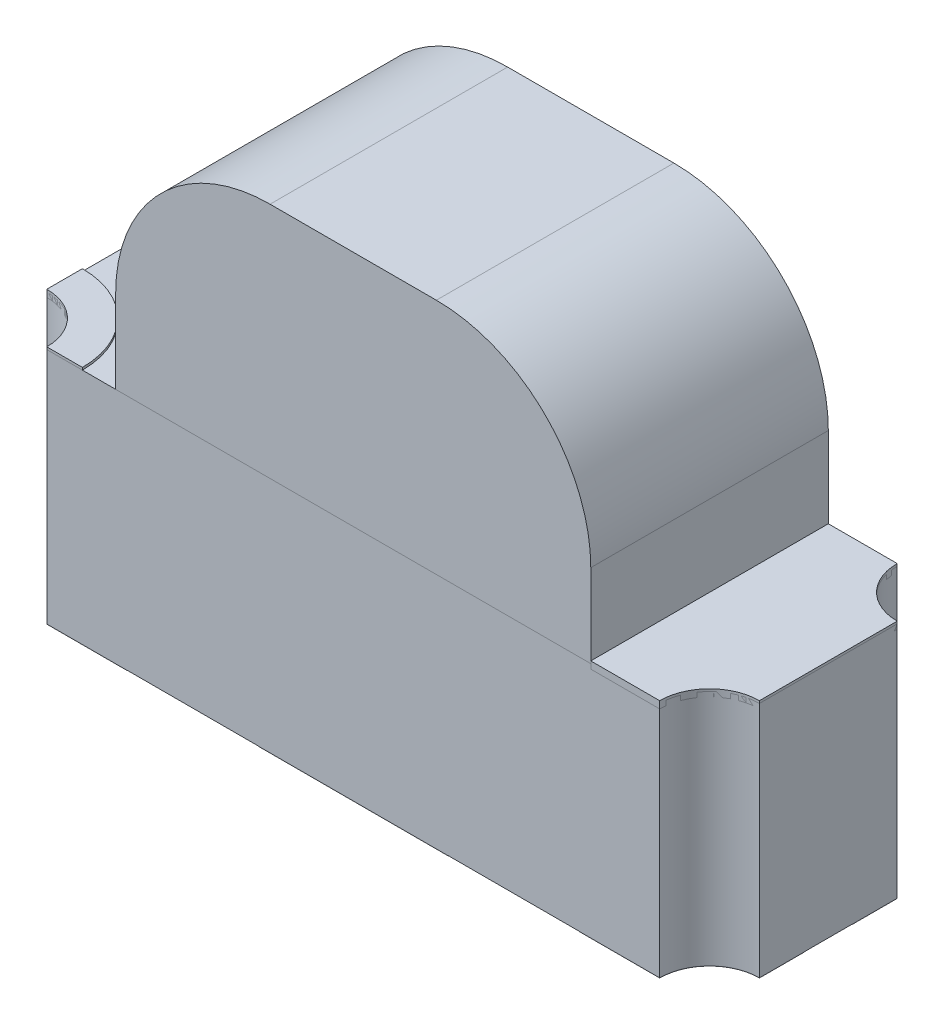
from build123d import *

# Parameters (mm, degrees)
SKETCH1_W             = 3
SKETCH1_H             = 1
EXTRUDE1_DEPTH        = 0.5
EXTRUDE4_DEPTH        = 0.001
EXTRUDE4_DEPTH_BACK   = 0.02
EXTRUDE4_2_DEPTH      = 0.001
EXTRUDE4_2_DEPTH_BACK = 0.02
EXTRUDE4_3_DEPTH      = 0.001
EXTRUDE4_3_DEPTH_BACK = 0.02
EXTRUDE4_4_DEPTH      = 0.001
EXTRUDE4_4_DEPTH_BACK = 0.02
EXTRUDE4_5_DEPTH      = 0.001
EXTRUDE4_5_DEPTH_BACK = 0.02
EXTRUDE5_DEPTH        = 0.01
EXTRUDE5_DEPTH_BACK   = 0.03
EXTRUDE6_DEPTH        = 0.5
EXTRUDE7_DEPTH        = 0.01
EXTRUDE7_DEPTH_BACK   = 0.02
EXTRUDE7_2_DEPTH      = 0.01
EXTRUDE7_2_DEPTH_BACK = 0.02
EXTRUDE7_3_DEPTH      = 0.01
EXTRUDE7_3_DEPTH_BACK = 0.02
CUT_EXTRUDE1_DEPTH    = 3
SKETCH7_W             = 0.013291139
SKETCH7_H             = 0.012658228
CUT_EXTRUDE2_DEPTH    = 0.01


with BuildPart() as part:
    # Sketch1 → Extrude1 (new body, symmetric)
    with BuildSketch(Plane.XY):
        Rectangle(SKETCH1_W, SKETCH1_H)
    extrude(amount=EXTRUDE1_DEPTH, both=True)

    # Sketch5_5 → Cut-Extrude1 (cut, through all)
    with BuildSketch(Plane.XZ.offset(0.5)):
        with BuildLine():
            ThreePointArc((-1.5, 0.29), (-1.351507576, 0.351507576), (-1.29, 0.5))
            Line((-1.29, 0.5), (-1.5, 0.5))
            Line((-1.5, 0.5), (-1.5, 0.29))
        make_face()
        with BuildLine():
            Line((1.5, 0.5), (1.29, 0.5))
            ThreePointArc((1.29, 0.5), (1.351507576, 0.351507576), (1.5, 0.29))
            Line((1.5, 0.29), (1.5, 0.5))
        make_face()
        with BuildLine():
            ThreePointArc((1.5, -0.29), (1.351507576, -0.351507576), (1.29, -0.5))
            Line((1.29, -0.5), (1.5, -0.5))
            Line((1.5, -0.5), (1.5, -0.29))
        make_face()
        with BuildLine():
            ThreePointArc((-1.29, -0.5), (-1.351507576, -0.351507576), (-1.5, -0.29))
            Line((-1.5, -0.29), (-1.5, -0.5))
            Line((-1.5, -0.5), (-1.29, -0.5))
        make_face()
    extrude(amount=-CUT_EXTRUDE1_DEPTH, mode=Mode.SUBTRACT)

    # Sketch7 → Cut-Extrude2 (cut)
    with BuildSketch(Plane.XZ.offset(0.5)):
        Polygon((0.80431435, -0.299056127), (0.841656122, -0.310784766), (0.841656122, -0.323156206), (0.816488005, -0.331364276), (0.841656122, -0.33912733), (0.841656122, -0.351993232), (0.80431435, -0.363613089), (0.80431435, -0.351024086), (0.830056043, -0.344526855), (0.80431435, -0.336318785), (0.80431435, -0.325569181), (0.830056043, -0.317410558), (0.80431435, -0.31100233), align=None)
        Polygon((0.80431435, -0.23196752), (0.841656122, -0.243696159), (0.841656122, -0.256067599), (0.816488005, -0.264275668), (0.841656122, -0.272038722), (0.841656122, -0.284904624), (0.80431435, -0.296524482), (0.80431435, -0.283935478), (0.830056043, -0.277438247), (0.80431435, -0.269230178), (0.80431435, -0.258480573), (0.830056043, -0.25032195), (0.80431435, -0.243913722), align=None)
        Polygon((0.80431435, -0.164878912), (0.841656122, -0.176607551), (0.841656122, -0.188978991), (0.816488005, -0.197187061), (0.841656122, -0.204950115), (0.841656122, -0.217816016), (0.80431435, -0.229435874), (0.80431435, -0.216846871), (0.830056043, -0.21034964), (0.80431435, -0.20214157), (0.80431435, -0.191391966), (0.830056043, -0.183233342), (0.80431435, -0.176825115), align=None)
        with Locations((0.835010553, -0.150954861)):
            Rectangle(SKETCH7_W, SKETCH7_H)
        with BuildLine():
            add(Edge.make_bspline(
                [(0.826070679, -0.092727013), (0.82668174, -0.092745273), (0.827881659, -0.092781128), (0.829635588, -0.093085775), (0.83129743, -0.093583296), (0.832878049, -0.094266354), (0.834360262, -0.095171037), (0.835758269, -0.096261689), (0.837065368, -0.097555443), (0.838269632, -0.099033633), (0.839371964, -0.10067418), (0.840317517, -0.102475421), (0.841130784, -0.104409919), (0.841796372, -0.106487117), (0.842291829, -0.108709852), (0.842653467, -0.111068756), (0.842890227, -0.113565426), (0.842911196, -0.11527722), (0.842921945, -0.116154624)],
                knots=[0, 0, 0, 0, 0.907462679, 1.781953809, 2.635804048, 3.480274448, 4.332887508, 5.208817748, 6.109340518, 7.059474472, 8.037577805, 9.041105121, 10.077237313, 11.152245627, 12.27748741, 13.457227022, 14.696666784, 16, 16, 16, 16], degree=3))
            add(Edge.make_bspline(
                [(0.842921945, -0.116154624), (0.842908312, -0.117163616), (0.84288191, -0.119117709), (0.842689224, -0.121951493), (0.842345249, -0.124583227), (0.841866959, -0.1270321), (0.841265316, -0.129334251), (0.840619994, -0.131550923), (0.839887704, -0.133691569), (0.839337636, -0.135078115), (0.839065141, -0.135764988)],
                knots=[0, 0, 0, 0, 1.203182053, 2.33017619, 3.384818652, 4.366208123, 5.30340534, 6.221361684, 7.118890722, 8, 8, 8, 8], degree=3))
            Line((0.839065141, -0.135764988), (0.82709916, -0.135764988))
            Line((0.82709916, -0.135764988), (0.82709916, -0.134340937))
            add(Edge.make_bspline(
                [(0.82709916, -0.134340937), (0.827639641, -0.133658156), (0.828717431, -0.132296601), (0.830101608, -0.130083122), (0.831288113, -0.127753616), (0.832279424, -0.125334419), (0.833067231, -0.122883735), (0.833630684, -0.120449201), (0.834000366, -0.11806471), (0.834041147, -0.116485549), (0.834061185, -0.115709608)],
                knots=[0, 0, 0, 0, 1.030738938, 2.055426519, 3.085610749, 4.123842265, 5.148648843, 6.130724483, 7.081507926, 8, 8, 8, 8], degree=3))
            add(Edge.make_bspline(
                [(0.834061185, -0.115709608), (0.834060517, -0.115495237), (0.834059087, -0.115036284), (0.83399903, -0.114304956), (0.83393383, -0.113480194), (0.833836831, -0.112592999), (0.833719645, -0.111696415), (0.833549054, -0.110862465), (0.833363, -0.110109082), (0.833179451, -0.10965573), (0.83309204, -0.10943983)],
                knots=[0, 0, 0, 0, 0.806557331, 1.726776592, 2.760222249, 3.920734434, 5.085813889, 6.161303184, 7.124353598, 8, 8, 8, 8], degree=3))
            add(Edge.make_bspline(
                [(0.83309204, -0.10943983), (0.832977763, -0.109200201), (0.832753186, -0.10872928), (0.832349854, -0.108078622), (0.831896448, -0.10750096), (0.831415754, -0.106972588), (0.830840431, -0.106529426), (0.830136829, -0.106220995), (0.829312836, -0.106047812), (0.828725157, -0.106028411), (0.828414429, -0.106018153)],
                knots=[0, 0, 0, 0, 1.025060442, 2.01446193, 2.949256246, 3.85908539, 4.768290539, 5.73153362, 6.800575992, 8, 8, 8, 8], degree=3))
            add(Edge.make_bspline(
                [(0.828414429, -0.106018153), (0.828141625, -0.106034085), (0.827605213, -0.106065412), (0.826837438, -0.106353865), (0.826133732, -0.106809164), (0.825497026, -0.107446151), (0.824937891, -0.108252546), (0.824426568, -0.109211337), (0.824012112, -0.110346862), (0.823792815, -0.111165268), (0.823677483, -0.111595684)],
                knots=[0, 0, 0, 0, 0.825786558, 1.623739628, 2.456775365, 3.355767579, 4.339087636, 5.42728423, 6.646958453, 8, 8, 8, 8], degree=3))
            add(Edge.make_bspline(
                [(0.823677483, -0.111595684), (0.823454628, -0.112580253), (0.822997258, -0.114600907), (0.822407711, -0.117671675), (0.821790385, -0.120740093), (0.821184676, -0.122715245), (0.820888717, -0.123680336)],
                knots=[0, 0, 0, 0, 0.976116373, 2.003306214, 3.02438349, 4, 4, 4, 4], degree=3))
            add(Edge.make_bspline(
                [(0.820888717, -0.123680336), (0.820711857, -0.124199414), (0.820367582, -0.125209847), (0.81979124, -0.126659426), (0.819138735, -0.127981108), (0.818477504, -0.12920968), (0.817738204, -0.130306694), (0.816967831, -0.131303551), (0.816148352, -0.132189703), (0.81526966, -0.132952458), (0.814352126, -0.133624682), (0.813378018, -0.134200195), (0.81234736, -0.134684253), (0.811265132, -0.135080469), (0.810130502, -0.135389885), (0.808941867, -0.135599957), (0.807700241, -0.135749305), (0.806853057, -0.135759689), (0.806420758, -0.135764988)],
                knots=[0, 0, 0, 0, 1.287139616, 2.505537848, 3.65787682, 4.745319116, 5.777517297, 6.75878323, 7.700384896, 8.605120322, 9.485712598, 10.366814604, 11.256335458, 12.154696155, 13.068779358, 14.012730507, 14.985940713, 16, 16, 16, 16], degree=3))
            add(Edge.make_bspline(
                [(0.806420758, -0.135764988), (0.805842685, -0.135746338), (0.804705047, -0.135709634), (0.803040536, -0.135408909), (0.801466127, -0.134895654), (0.799964549, -0.134202474), (0.798557417, -0.133288728), (0.797218674, -0.132192666), (0.795972426, -0.130887511), (0.794823108, -0.129394848), (0.793783705, -0.127751424), (0.792865351, -0.125984422), (0.792112127, -0.124094996), (0.791471512, -0.122105053), (0.790995314, -0.119995357), (0.790635525, -0.117776872), (0.790429025, -0.115439941), (0.790403387, -0.113844235), (0.790390299, -0.113029624)],
                knots=[0, 0, 0, 0, 0.894901293, 1.761149761, 2.608783409, 3.453876344, 4.314933854, 5.200038827, 6.12799933, 7.103249695, 8.113098521, 9.136064399, 10.182719798, 11.259667356, 12.370545059, 13.528828137, 14.738461593, 16, 16, 16, 16], degree=3))
            add(Edge.make_bspline(
                [(0.790390299, -0.113029624), (0.790401476, -0.112195295), (0.790423812, -0.110528051), (0.790611583, -0.108037115), (0.790893382, -0.105561449), (0.791296873, -0.103126369), (0.791801605, -0.100784303), (0.792346329, -0.098573064), (0.792966291, -0.096533531), (0.793443343, -0.095246675), (0.793673527, -0.094625747)],
                knots=[0, 0, 0, 0, 1.065384654, 2.128962885, 3.18847586, 4.246683315, 5.279600907, 6.247539799, 7.154412252, 8, 8, 8, 8], degree=3))
            Line((0.793673527, -0.094625747), (0.804947261, -0.094625747))
            Line((0.804947261, -0.094625747), (0.804947261, -0.096039909))
            add(Edge.make_bspline(
                [(0.804947261, -0.096039909), (0.804547689, -0.096576688), (0.803732252, -0.097672133), (0.802680235, -0.099496494), (0.801714383, -0.101483224), (0.800849719, -0.103617065), (0.800140153, -0.10585371), (0.799625435, -0.108142383), (0.799305924, -0.110455942), (0.799269351, -0.112006734), (0.799251059, -0.112782393)],
                knots=[0, 0, 0, 0, 0.892231706, 1.82084296, 2.804411717, 3.838445872, 4.890103822, 5.931567007, 6.965432763, 8, 8, 8, 8], degree=3))
            add(Edge.make_bspline(
                [(0.799251059, -0.112782393), (0.799263383, -0.113330012), (0.799288096, -0.114428101), (0.799459836, -0.116065801), (0.799799687, -0.117682387), (0.80020524, -0.118700923), (0.8004081, -0.119210399)],
                knots=[0, 0, 0, 0, 0.99896713, 2.003134239, 3.001159596, 4, 4, 4, 4], degree=3))
            add(Edge.make_bspline(
                [(0.8004081, -0.119210399), (0.800508697, -0.119427252), (0.800709825, -0.119860813), (0.80109952, -0.120464764), (0.80155814, -0.121024561), (0.802084773, -0.121526833), (0.802675306, -0.121938903), (0.803306642, -0.122259542), (0.803988108, -0.122439257), (0.804455128, -0.122462269), (0.804690141, -0.122473849)],
                knots=[0, 0, 0, 0, 1.005120364, 2.009570296, 3.014977851, 4.045438181, 5.061509448, 6.035608779, 7.011484765, 8, 8, 8, 8], degree=3))
            add(Edge.make_bspline(
                [(0.804690141, -0.122473849), (0.805009106, -0.122456452), (0.80561862, -0.122423207), (0.806475469, -0.122123208), (0.807207024, -0.121624374), (0.807703521, -0.121047824), (0.808052901, -0.120489335), (0.808305521, -0.119969076), (0.808562232, -0.119369351), (0.808806831, -0.118680626), (0.809053854, -0.117913059), (0.809291189, -0.117058598), (0.809515969, -0.116117294), (0.809659045, -0.115459349), (0.809733654, -0.115116254)],
                knots=[0, 0, 0, 0, 1.174343879, 2.244064321, 3.303704314, 4.407076671, 5.02483983, 5.732197225, 6.53898402, 7.431906431, 8.428480183, 9.514816237, 10.704066255, 12, 12, 12, 12], degree=3))
            add(Edge.make_bspline(
                [(0.809733654, -0.115116254), (0.809921704, -0.114199874), (0.810290533, -0.112402551), (0.810842148, -0.109701007), (0.81149358, -0.106953356), (0.812059776, -0.105115171), (0.812354302, -0.104158975)],
                knots=[0, 0, 0, 0, 0.995794372, 1.953081347, 2.935223864, 4, 4, 4, 4], degree=3))
            add(Edge.make_bspline(
                [(0.812354302, -0.104158975), (0.81251398, -0.10368573), (0.812826337, -0.102759986), (0.813368697, -0.101439228), (0.813959679, -0.100214645), (0.814571141, -0.099075709), (0.815251987, -0.098043974), (0.815960653, -0.097101557), (0.81671364, -0.096252975), (0.817521316, -0.09550841), (0.818376655, -0.094844409), (0.819301481, -0.094286907), (0.820276062, -0.093793599), (0.821316279, -0.09339779), (0.82242176, -0.093105551), (0.823585202, -0.092889212), (0.824807778, -0.092743607), (0.825645013, -0.092732606), (0.826070679, -0.092727013)],
                knots=[0, 0, 0, 0, 1.237247399, 2.420255609, 3.534416354, 4.605351393, 5.620193117, 6.593738998, 7.524982051, 8.426564095, 9.311945829, 10.20281032, 11.097671666, 12.01534975, 12.954438892, 13.926750701, 14.945921247, 16, 16, 16, 16], degree=3))
        make_face()
        with BuildLine():
            Line((0.841656122, -0.046524482), (0.841656122, -0.058549798))
            Line((0.841656122, -0.058549798), (0.837739983, -0.058549798))
            add(Edge.make_bspline(
                [(0.837739983, -0.058549798), (0.838144434, -0.059096369), (0.838924211, -0.060150148), (0.839962018, -0.061737781), (0.840858181, -0.063248265), (0.841611193, -0.064717479), (0.84222502, -0.06621718), (0.842631097, -0.06783426), (0.842883138, -0.069584773), (0.842908722, -0.070798349), (0.842921945, -0.071425589)],
                knots=[0, 0, 0, 0, 1.15097647, 2.219065785, 3.209751872, 4.123278731, 5.012494873, 5.946522673, 6.938654008, 8, 8, 8, 8], degree=3))
            add(Edge.make_bspline(
                [(0.842921945, -0.071425589), (0.842910466, -0.071933723), (0.842888113, -0.072923208), (0.842717322, -0.074362402), (0.842442872, -0.075713228), (0.842059531, -0.076978198), (0.841553824, -0.078153711), (0.840928475, -0.079232551), (0.840197541, -0.080225884), (0.839359414, -0.081127711), (0.838398841, -0.081922983), (0.837337491, -0.082616519), (0.836170164, -0.083204422), (0.834894483, -0.083675242), (0.83351526, -0.084052708), (0.832025657, -0.084314697), (0.830432087, -0.084474987), (0.829334523, -0.084490957), (0.828770442, -0.084499165)],
                knots=[0, 0, 0, 0, 1.108887696, 2.159324556, 3.158383213, 4.114277414, 5.039206009, 5.945047284, 6.830075132, 7.726032535, 8.625162295, 9.545152215, 10.487958828, 11.471559655, 12.508379831, 13.604991163, 14.769110247, 16, 16, 16, 16], degree=3))
            Line((0.828770442, -0.084499165), (0.80431435, -0.084499165))
            Line((0.80431435, -0.084499165), (0.80431435, -0.072473849))
            Line((0.80431435, -0.072473849), (0.823103907, -0.072473849))
            add(Edge.make_bspline(
                [(0.823103907, -0.072473849), (0.823562142, -0.072473031), (0.82443925, -0.072471466), (0.825692153, -0.072430296), (0.82682624, -0.072369846), (0.827847254, -0.072300494), (0.828770629, -0.072173985), (0.82960371, -0.071985131), (0.830363511, -0.071749718), (0.830816861, -0.071517558), (0.831035078, -0.071405811)],
                knots=[0, 0, 0, 0, 1.361401701, 2.605856924, 3.723918663, 4.735739235, 5.645738665, 6.489217889, 7.27279937, 8, 8, 8, 8], degree=3))
            add(Edge.make_bspline(
                [(0.831035078, -0.071405811), (0.831234397, -0.07129079), (0.831626241, -0.071064669), (0.832129882, -0.070604776), (0.832548078, -0.070066735), (0.832885427, -0.069432114), (0.833123008, -0.068684054), (0.833316598, -0.0678216), (0.833401706, -0.066825404), (0.833419077, -0.066121719), (0.833428274, -0.065749165)],
                knots=[0, 0, 0, 0, 0.848923305, 1.668910138, 2.502822694, 3.358979167, 4.311113223, 5.396624103, 6.621686681, 8, 8, 8, 8], degree=3))
            add(Edge.make_bspline(
                [(0.833428274, -0.065749165), (0.8334183, -0.065478705), (0.833397807, -0.064923019), (0.833303291, -0.064067325), (0.833101211, -0.063176505), (0.832779226, -0.061917328), (0.832185745, -0.060329982), (0.831506982, -0.059147793), (0.831163638, -0.058549798)],
                knots=[0, 0, 0, 0, 0.638098464, 1.31103257, 2.025970928, 2.789492669, 4.376004971, 6, 6, 6, 6], degree=3))
            Line((0.831163638, -0.058549798), (0.80431435, -0.058549798))
            Line((0.80431435, -0.058549798), (0.80431435, -0.046524482))
            Line((0.80431435, -0.046524482), (0.841656122, -0.046524482))
        make_face()
        with BuildLine():
            Line((0.841656122, 0.002209696), (0.841656122, -0.009815621))
            Line((0.841656122, -0.009815621), (0.822866565, -0.009815621))
            add(Edge.make_bspline(
                [(0.822866565, -0.009815621), (0.822101354, -0.009826026), (0.820571912, -0.009846823), (0.818693211, -0.010010927), (0.817269673, -0.010180662), (0.816354798, -0.010368041), (0.815580639, -0.010583212), (0.815137769, -0.010789427), (0.814935394, -0.010883659)],
                knots=[0, 0, 0, 0, 1.709225407, 3.416259723, 4.21101956, 4.910102269, 5.501957085, 6, 6, 6, 6], degree=3))
            add(Edge.make_bspline(
                [(0.814935394, -0.010883659), (0.814736328, -0.011005872), (0.814346031, -0.011245489), (0.813840089, -0.01171441), (0.813421717, -0.012262682), (0.813090292, -0.012902249), (0.812843088, -0.013643042), (0.812669947, -0.014502957), (0.812563836, -0.015492724), (0.812549686, -0.016197188), (0.812542198, -0.016569972)],
                knots=[0, 0, 0, 0, 0.860284341, 1.686708632, 2.528476982, 3.393563585, 4.332150703, 5.400907339, 6.624626855, 8, 8, 8, 8], degree=3))
            add(Edge.make_bspline(
                [(0.812542198, -0.016569972), (0.81257217, -0.01713545), (0.812633332, -0.018289367), (0.812967699, -0.019726574), (0.813394313, -0.020883392), (0.813777271, -0.021808785), (0.81425592, -0.022766593), (0.814619266, -0.02340837), (0.814806834, -0.023739671)],
                knots=[0, 0, 0, 0, 1.338233385, 2.730803257, 3.468495571, 4.255080394, 5.099229486, 6, 6, 6, 6], degree=3))
            Line((0.814806834, -0.023739671), (0.841656122, -0.023739671))
            Line((0.841656122, -0.023739671), (0.841656122, -0.035764988))
            Line((0.841656122, -0.035764988), (0.80431435, -0.035764988))
            Line((0.80431435, -0.035764988), (0.80431435, -0.023739671))
            Line((0.80431435, -0.023739671), (0.808230489, -0.023739671))
            add(Edge.make_bspline(
                [(0.808230489, -0.023739671), (0.80782727, -0.023211053), (0.807042381, -0.022182065), (0.806025676, -0.020593689), (0.805120748, -0.019058333), (0.80436468, -0.017531072), (0.80376538, -0.015968823), (0.803357579, -0.014335008), (0.803086105, -0.012626651), (0.803061199, -0.011458315), (0.803048527, -0.01086388)],
                knots=[0, 0, 0, 0, 1.126064518, 2.191951536, 3.19307265, 4.144813015, 5.076393104, 6.021983703, 6.993610568, 8, 8, 8, 8], degree=3))
            add(Edge.make_bspline(
                [(0.803048527, -0.01086388), (0.803061227, -0.010365748), (0.80308602, -0.009393305), (0.803240796, -0.00797588), (0.803516408, -0.006640327), (0.803914336, -0.005393634), (0.804410016, -0.004225793), (0.805012003, -0.003138951), (0.805743652, -0.002146048), (0.806573591, -0.001231889), (0.807519355, -0.000412657), (0.8085836, 0.000287024), (0.809754844, 0.00088496), (0.811029616, 0.00137862), (0.812419095, 0.001754139), (0.813915786, 0.002012231), (0.815521234, 0.00218937), (0.816629237, 0.002202785), (0.81720003, 0.002209696)],
                knots=[0, 0, 0, 0, 1.088244909, 2.124447647, 3.110254678, 4.062235362, 4.978491991, 5.877983887, 6.769571508, 7.666696544, 8.570415953, 9.495151274, 10.442024977, 11.43832337, 12.476026402, 13.580659577, 14.753665747, 16, 16, 16, 16], degree=3))
            Line((0.81720003, 0.002209696), (0.841656122, 0.002209696))
        make_face()
        Polygon((0.841656122, 0.04967805), (0.841656122, 0.013602101), (0.791656122, 0.013602101), (0.791656122, 0.026260329), (0.832162451, 0.026260329), (0.832162451, 0.04967805), align=None)
        Polygon((0.841656122, 0.093348936), (0.841656122, 0.057272987), (0.791656122, 0.057272987), (0.791656122, 0.093348936), (0.801149793, 0.093348936), (0.801149793, 0.069931215), (0.810010552, 0.069931215), (0.810010552, 0.091450202), (0.819504223, 0.091450202), (0.819504223, 0.069931215), (0.832162451, 0.069931215), (0.832162451, 0.093348936), align=None)
        with BuildLine():
            add(Edge.make_bspline(
                [(0.816705568, 0.151576784), (0.817279413, 0.151567127), (0.818415856, 0.151548), (0.820098259, 0.151400405), (0.821731097, 0.151137392), (0.823323221, 0.150797802), (0.824862685, 0.150336549), (0.826366473, 0.149795692), (0.82781922, 0.149140869), (0.829219937, 0.148388443), (0.830555989, 0.147563706), (0.831816093, 0.146676332), (0.833007702, 0.145753442), (0.834105149, 0.144758786), (0.835126159, 0.143719195), (0.836071566, 0.142631431), (0.836923281, 0.141478899), (0.837434723, 0.140675317), (0.837690536, 0.140273382)],
                knots=[0, 0, 0, 0, 1.105570398, 2.18947457, 3.250358341, 4.290584537, 5.323553275, 6.344225964, 7.367641686, 8.3905646, 9.405808457, 10.390761353, 11.358902336, 12.307789878, 13.241960776, 14.165076779, 15.082208636, 16, 16, 16, 16], degree=3))
            add(Edge.make_bspline(
                [(0.837690536, 0.140273382), (0.838046712, 0.139653792), (0.83876088, 0.138411451), (0.839593576, 0.136419168), (0.840302594, 0.134355534), (0.840806199, 0.132171877), (0.841191938, 0.129852833), (0.84146718, 0.127353811), (0.841619228, 0.124653588), (0.841643544, 0.122786097), (0.841656122, 0.12182006)],
                knots=[0, 0, 0, 0, 0.896331627, 1.797236794, 2.705411718, 3.632841792, 4.606367508, 5.655603524, 6.787262262, 8, 8, 8, 8], degree=3))
            Line((0.841656122, 0.12182006), (0.841656122, 0.10410843))
            Line((0.841656122, 0.10410843), (0.791656122, 0.10410843))
            Line((0.791656122, 0.10410843), (0.791656122, 0.122324411))
            add(Edge.make_bspline(
                [(0.791656122, 0.122324411), (0.791664569, 0.123313755), (0.791680863, 0.125222077), (0.791887518, 0.127977524), (0.792191728, 0.130525283), (0.792639732, 0.132869688), (0.793193675, 0.135025117), (0.79388991, 0.13698653), (0.794636002, 0.138794704), (0.795273306, 0.139883964), (0.79558215, 0.140411832)],
                knots=[0, 0, 0, 0, 1.267100211, 2.444079055, 3.537724964, 4.552266402, 5.499704501, 6.385138932, 7.217420793, 8, 8, 8, 8], degree=3))
            add(Edge.make_bspline(
                [(0.79558215, 0.140411832), (0.795850421, 0.140837308), (0.796383877, 0.141683371), (0.797274804, 0.142883978), (0.798252842, 0.143998692), (0.799278751, 0.145062943), (0.800380195, 0.14605285), (0.801549547, 0.146974457), (0.802788601, 0.14782634), (0.80409331, 0.148605418), (0.80545843, 0.149315461), (0.806894603, 0.1499115), (0.80838604, 0.150431181), (0.809935509, 0.150854222), (0.811544204, 0.151182387), (0.813212944, 0.151405429), (0.814939538, 0.151547146), (0.816111935, 0.151566822), (0.816705568, 0.151576784)],
                knots=[0, 0, 0, 0, 0.964043478, 1.917004671, 2.862223898, 3.805158963, 4.749279098, 5.698713747, 6.657523689, 7.629652222, 8.610369353, 9.604453025, 10.607693792, 11.636365947, 12.681120053, 13.752669011, 14.862083412, 16, 16, 16, 16], degree=3))
        make_face()
        with BuildLine():
            add(Edge.make_bspline(
                [(0.816626454, 0.138285645), (0.815837526, 0.138262444), (0.814314692, 0.13821766), (0.812112591, 0.137885888), (0.810095959, 0.137296123), (0.808537707, 0.136631505), (0.807401199, 0.135962232), (0.806602034, 0.135398586), (0.805844942, 0.134773722), (0.80514052, 0.134078425), (0.804487003, 0.133310831), (0.803872547, 0.132480202), (0.803308224, 0.131580182), (0.802978221, 0.130943666), (0.802811185, 0.130621484)],
                knots=[0, 0, 0, 0, 1.694561208, 3.270940604, 4.767926833, 6.198032689, 6.896357436, 7.597727349, 8.296769799, 9.00280713, 9.720956486, 10.460265288, 11.220639329, 12, 12, 12, 12], degree=3))
            add(Edge.make_bspline(
                [(0.802811185, 0.130621484), (0.802657928, 0.130284016), (0.802354162, 0.129615132), (0.801987118, 0.128579994), (0.801705955, 0.127533643), (0.801469743, 0.12643653), (0.801331175, 0.12519815), (0.801224837, 0.123736904), (0.801156373, 0.122008568), (0.801152088, 0.12076527), (0.801149793, 0.120099332)],
                knots=[0, 0, 0, 0, 0.826913061, 1.638999358, 2.447478739, 3.243919028, 4.140906711, 5.225381046, 6.513851968, 8, 8, 8, 8], degree=3))
            Line((0.801149793, 0.120099332), (0.801149793, 0.116766658))
            Line((0.801149793, 0.116766658), (0.832162451, 0.116766658))
            Line((0.832162451, 0.116766658), (0.832162451, 0.120099332))
            add(Edge.make_bspline(
                [(0.832162451, 0.120099332), (0.83215993, 0.120478427), (0.832155063, 0.121210296), (0.832135487, 0.122268519), (0.832105412, 0.12325091), (0.832069213, 0.124154553), (0.832012888, 0.124979454), (0.831925893, 0.125723051), (0.831857544, 0.126391456), (0.831718983, 0.127177715), (0.831515859, 0.1281053), (0.831174323, 0.129188697), (0.830749525, 0.130259046), (0.830406987, 0.130953322), (0.830234049, 0.131303841)],
                knots=[0, 0, 0, 0, 1.186788252, 2.291168447, 3.31326867, 4.263560303, 5.122314491, 5.900668105, 6.60723418, 7.224768558, 8.398927205, 9.577205322, 10.776800932, 12, 12, 12, 12], degree=3))
            add(Edge.make_bspline(
                [(0.830234049, 0.131303841), (0.83006231, 0.131595697), (0.829724567, 0.132169663), (0.829171647, 0.132991753), (0.828554105, 0.133735058), (0.827912709, 0.134438322), (0.82721692, 0.135063902), (0.826495149, 0.135652552), (0.825707878, 0.136145172), (0.824613411, 0.136769607), (0.823099832, 0.137391395), (0.821113871, 0.137908202), (0.818934293, 0.138227599), (0.81741544, 0.1382658), (0.816626454, 0.138285645)],
                knots=[0, 0, 0, 0, 0.755184287, 1.485151634, 2.206180267, 2.908413556, 3.605665444, 4.291074465, 4.982332562, 5.673512475, 7.100235687, 8.614142391, 10.24117603, 12, 12, 12, 12], degree=3))
        make_face(mode=Mode.SUBTRACT)
        with Locations((0.835010553, 0.167399569)):
            Rectangle(SKETCH7_W, SKETCH7_H)
        with BuildLine():
            add(Edge.make_bspline(
                [(0.842921945, 0.204721563), (0.842911035, 0.203926508), (0.842889622, 0.202365943), (0.842651216, 0.200080248), (0.842292181, 0.19789775), (0.841782392, 0.19582428), (0.841107706, 0.193872638), (0.84029017, 0.192036446), (0.83929025, 0.190336843), (0.838498942, 0.189303351), (0.838105885, 0.188789996)],
                knots=[0, 0, 0, 0, 1.123640227, 2.2055255, 3.245221982, 4.248949655, 5.220213072, 6.160941522, 7.086505793, 8, 8, 8, 8], degree=3))
            add(Edge.make_bspline(
                [(0.838105885, 0.188789996), (0.837678468, 0.188314179), (0.836825288, 0.187364384), (0.835340016, 0.186130571), (0.83369553, 0.185071532), (0.831899703, 0.184165405), (0.82993976, 0.183449429), (0.827814813, 0.182953161), (0.825536149, 0.18263936), (0.823962046, 0.182606384), (0.823153353, 0.182589442)],
                knots=[0, 0, 0, 0, 0.916342154, 1.829140869, 2.758848968, 3.716597128, 4.708179637, 5.743612459, 6.840783343, 8, 8, 8, 8], degree=3))
            add(Edge.make_bspline(
                [(0.823153353, 0.182589442), (0.822301739, 0.182608823), (0.820651199, 0.182646384), (0.818265106, 0.182978264), (0.816056265, 0.18351307), (0.814030311, 0.184281849), (0.812183715, 0.18524707), (0.810497798, 0.186379316), (0.808976336, 0.187689579), (0.808103616, 0.188693148), (0.807666802, 0.189195455)],
                knots=[0, 0, 0, 0, 1.171797512, 2.271099083, 3.308930235, 4.294129479, 5.24602549, 6.17106565, 7.084581485, 8, 8, 8, 8], degree=3))
            add(Edge.make_bspline(
                [(0.807666802, 0.189195455), (0.807282475, 0.189708369), (0.806509179, 0.190740391), (0.805560819, 0.192439831), (0.804761836, 0.194248168), (0.804124356, 0.196159809), (0.803649734, 0.19815116), (0.803301851, 0.20018588), (0.80308778, 0.202257838), (0.803061674, 0.203653021), (0.803048527, 0.204355661)],
                knots=[0, 0, 0, 0, 0.952013349, 1.915525331, 2.885385798, 3.888123097, 4.906830296, 5.926067872, 6.955529031, 8, 8, 8, 8], degree=3))
            add(Edge.make_bspline(
                [(0.803048527, 0.204355661), (0.803056706, 0.204979067), (0.803072789, 0.206204895), (0.803238368, 0.208004258), (0.803487877, 0.209730257), (0.803859662, 0.211379902), (0.804321069, 0.212963001), (0.804833143, 0.214494726), (0.805403098, 0.215976844), (0.805845077, 0.216927221), (0.806064745, 0.217399569)],
                knots=[0, 0, 0, 0, 1.107572103, 2.177862056, 3.208491727, 4.204802822, 5.180069889, 6.137814326, 7.074472616, 8, 8, 8, 8], degree=3))
            Line((0.806064745, 0.217399569), (0.816339666, 0.217399569))
            Line((0.816339666, 0.217399569), (0.816339666, 0.215728287))
            add(Edge.make_bspline(
                [(0.816339666, 0.215728287), (0.81613122, 0.215478389), (0.815677752, 0.214934744), (0.814964309, 0.214043831), (0.814203677, 0.212966376), (0.813759343, 0.212144041), (0.813521233, 0.211703366)],
                knots=[0, 0, 0, 0, 0.792806788, 1.724728901, 2.780722718, 4, 4, 4, 4], degree=3))
            add(Edge.make_bspline(
                [(0.813521233, 0.211703366), (0.81330146, 0.211239037), (0.812849214, 0.210283544), (0.812417072, 0.209009984), (0.812149081, 0.207909823), (0.812018069, 0.207005848), (0.811924262, 0.206038792), (0.81191437, 0.205371206), (0.811909286, 0.205028129)],
                knots=[0, 0, 0, 0, 1.332411269, 2.741822805, 3.48048496, 4.268099981, 5.109965479, 6, 6, 6, 6], degree=3))
            add(Edge.make_bspline(
                [(0.811909286, 0.205028129), (0.811918957, 0.204645313), (0.811937697, 0.203903434), (0.812077654, 0.202823203), (0.81231194, 0.201811062), (0.812650062, 0.200866447), (0.813080214, 0.199989167), (0.813590294, 0.199171332), (0.814216289, 0.198433511), (0.814925505, 0.197762698), (0.815720667, 0.197168912), (0.816583937, 0.196655548), (0.817512876, 0.196214181), (0.818511832, 0.195863235), (0.819576763, 0.19558448), (0.820708168, 0.195389698), (0.821907967, 0.195268808), (0.822731115, 0.195254837), (0.823153353, 0.19524767)],
                knots=[0, 0, 0, 0, 1.087164589, 2.106874378, 3.088024391, 4.032801718, 4.949890679, 5.859058447, 6.763003849, 7.690312844, 8.626654282, 9.575690722, 10.539030902, 11.54301425, 12.578634972, 13.662366762, 14.800897888, 16, 16, 16, 16], degree=3))
            add(Edge.make_bspline(
                [(0.823153353, 0.19524767), (0.823585431, 0.195255057), (0.824424937, 0.19526941), (0.825645743, 0.195386168), (0.826786458, 0.195594113), (0.827849118, 0.195879737), (0.828832128, 0.196241911), (0.829730826, 0.19669447), (0.83055923, 0.197212648), (0.831290535, 0.197834927), (0.831948696, 0.198516869), (0.832516763, 0.199274315), (0.832990836, 0.200103934), (0.833393068, 0.200995024), (0.833682267, 0.201961545), (0.833900613, 0.202989813), (0.834044891, 0.204084591), (0.834055672, 0.204839768), (0.834061185, 0.205225914)],
                knots=[0, 0, 0, 0, 1.230336593, 2.390482092, 3.487897344, 4.52859895, 5.520747884, 6.465347575, 7.38981449, 8.296085817, 9.192433006, 10.084246191, 10.984321635, 11.908883871, 12.862027947, 13.850751296, 14.901019963, 16, 16, 16, 16], degree=3))
            add(Edge.make_bspline(
                [(0.834061185, 0.205225914), (0.834056758, 0.205588789), (0.834048127, 0.2062962), (0.833944405, 0.207326561), (0.833789211, 0.208301774), (0.833568395, 0.209217909), (0.833315795, 0.210073703), (0.833027197, 0.210854519), (0.832725874, 0.21156108), (0.832491967, 0.211991716), (0.832380014, 0.212197829)],
                knots=[0, 0, 0, 0, 1.201100869, 2.341500598, 3.425337164, 4.468451875, 5.459559168, 6.378110228, 7.223726512, 8, 8, 8, 8], degree=3))
            add(Edge.make_bspline(
                [(0.832380014, 0.212197829), (0.832166171, 0.212552007), (0.831755192, 0.213232693), (0.831044962, 0.214145253), (0.830341742, 0.214967315), (0.829863358, 0.215479368), (0.829630805, 0.215728287)],
                knots=[0, 0, 0, 0, 1.105932972, 2.12546697, 3.088749538, 4, 4, 4, 4], degree=3))
            Line((0.829630805, 0.215728287), (0.829630805, 0.217399569))
            Line((0.829630805, 0.217399569), (0.83998484, 0.217399569))
            add(Edge.make_bspline(
                [(0.83998484, 0.217399569), (0.840203611, 0.216926881), (0.840641206, 0.21598139), (0.841217781, 0.214524002), (0.841704221, 0.21302738), (0.842150394, 0.211501765), (0.842499492, 0.209916949), (0.842744107, 0.208258275), (0.842894976, 0.206517622), (0.842912833, 0.205328414), (0.842921945, 0.204721563)],
                knots=[0, 0, 0, 0, 0.952024047, 1.90427691, 2.862762905, 3.827874523, 4.80891974, 5.826446878, 6.890837857, 8, 8, 8, 8], degree=3))
        make_face()
        with BuildLine():
            add(Edge.make_bspline(
                [(0.823005014, 0.263602101), (0.82375743, 0.263589641), (0.825224091, 0.263565353), (0.827360501, 0.263297249), (0.829375722, 0.262885518), (0.83127614, 0.262318855), (0.833047663, 0.261559929), (0.83469564, 0.260638722), (0.836221731, 0.259551926), (0.837616845, 0.258306767), (0.838865941, 0.256906024), (0.839964037, 0.255369141), (0.840867561, 0.253684208), (0.841630836, 0.251879835), (0.842208887, 0.249935182), (0.842617862, 0.247855634), (0.842885028, 0.245646879), (0.842909434, 0.244127697), (0.842921945, 0.243348936)],
                knots=[0, 0, 0, 0, 1.120122129, 2.18341868, 3.201215738, 4.181270334, 5.131540819, 6.065757527, 6.988093576, 7.916512302, 8.844931028, 9.778115023, 10.722851943, 11.686686084, 12.691660064, 13.738321946, 14.84062285, 16, 16, 16, 16], degree=3))
            add(Edge.make_bspline(
                [(0.842921945, 0.243348936), (0.842909475, 0.242570162), (0.842885149, 0.241050953), (0.842617414, 0.238842386), (0.842211055, 0.236765276), (0.841626438, 0.23482295), (0.840870392, 0.233015795), (0.839963671, 0.231328881), (0.838866045, 0.22979179), (0.83761679, 0.228391189), (0.836221847, 0.22714567), (0.834695232, 0.226060168), (0.833050336, 0.225134698), (0.831271699, 0.224394502), (0.829378095, 0.223808237), (0.827360096, 0.223401847), (0.8252242, 0.223132188), (0.823757467, 0.223108119), (0.823005014, 0.223095772)],
                knots=[0, 0, 0, 0, 1.159424321, 2.261770074, 3.308474541, 4.308788811, 5.277191138, 6.221966496, 7.15518846, 8.08364496, 9.01210146, 9.934475036, 10.868729753, 11.817121636, 12.798654016, 13.816492484, 14.879832297, 16, 16, 16, 16], degree=3))
            add(Edge.make_bspline(
                [(0.823005014, 0.223095772), (0.822249298, 0.223108322), (0.820772784, 0.223132844), (0.81862341, 0.223400678), (0.816592862, 0.223809159), (0.814686587, 0.224391925), (0.812905349, 0.225145063), (0.811252254, 0.226068536), (0.809728868, 0.227166414), (0.808333785, 0.228421131), (0.807086521, 0.229827514), (0.805997469, 0.231371263), (0.805093072, 0.233053033), (0.80432919, 0.234853209), (0.803762917, 0.23679704), (0.803353839, 0.238865353), (0.803084884, 0.241064095), (0.803060867, 0.242573458), (0.803048527, 0.243348936)],
                knots=[0, 0, 0, 0, 1.123883205, 2.195836198, 3.217400301, 4.202580581, 5.156396106, 6.089661422, 7.013912723, 7.944661364, 8.875797629, 9.805201257, 10.748976071, 11.711828658, 12.709674189, 13.755270167, 14.846705509, 16, 16, 16, 16], degree=3))
            add(Edge.make_bspline(
                [(0.803048527, 0.243348936), (0.803060883, 0.244134308), (0.80308494, 0.245663396), (0.803353109, 0.247885061), (0.803759372, 0.249972126), (0.804343407, 0.25192093), (0.805095042, 0.253732934), (0.806022515, 0.255406522), (0.80710969, 0.256949002), (0.808374605, 0.258333133), (0.809772082, 0.259575012), (0.811300922, 0.26065619), (0.812954709, 0.261573929), (0.814735647, 0.2623118), (0.816631963, 0.262898901), (0.818649177, 0.263309107), (0.82078663, 0.263562183), (0.822252701, 0.263588563), (0.823005014, 0.263602101)],
                knots=[0, 0, 0, 0, 1.167473013, 2.273023816, 3.322954552, 4.326451713, 5.293391623, 6.234801871, 7.166614545, 8.093305908, 9.017100806, 9.942078766, 10.872536262, 11.824015763, 12.804065898, 13.820367293, 14.881523901, 16, 16, 16, 16], degree=3))
        make_face()
        with BuildLine():
            add(Edge.make_bspline(
                [(0.832251454, 0.248748461), (0.832001322, 0.248925749), (0.831492274, 0.249286551), (0.830642525, 0.249727278), (0.829721632, 0.250102434), (0.828709252, 0.250412852), (0.82756408, 0.250670253), (0.826238604, 0.250819547), (0.824721229, 0.250936323), (0.823644814, 0.250941257), (0.823074239, 0.250943873)],
                knots=[0, 0, 0, 0, 0.765135464, 1.557141201, 2.384449913, 3.246599353, 4.1996426, 5.311961702, 6.575150963, 8, 8, 8, 8], degree=3))
            add(Edge.make_bspline(
                [(0.823074239, 0.250943873), (0.822536802, 0.250935006), (0.821507131, 0.250918018), (0.820027199, 0.250825126), (0.81868245, 0.250649396), (0.817470096, 0.250402638), (0.816384061, 0.250098843), (0.815417897, 0.249731442), (0.814560919, 0.249314723), (0.814058359, 0.248971846), (0.81381791, 0.248807797)],
                knots=[0, 0, 0, 0, 1.337015307, 2.56157572, 3.686511827, 4.707709802, 5.636963675, 6.488272502, 7.276717686, 8, 8, 8, 8], degree=3))
            add(Edge.make_bspline(
                [(0.81381791, 0.248807797), (0.813599087, 0.248638465), (0.813171716, 0.248307753), (0.812618556, 0.247729503), (0.812183652, 0.247085752), (0.811831286, 0.246403281), (0.811593238, 0.24567544), (0.811410445, 0.244925341), (0.811301233, 0.244146542), (0.811284707, 0.243616273), (0.811276375, 0.243348936)],
                knots=[0, 0, 0, 0, 1.058303018, 2.066917725, 3.046948061, 4.023234392, 4.996907708, 5.970172105, 6.976653347, 8, 8, 8, 8], degree=3))
            add(Edge.make_bspline(
                [(0.811276375, 0.243348936), (0.81128189, 0.243084985), (0.811292677, 0.242568705), (0.811381936, 0.241817167), (0.811531935, 0.24110934), (0.811734028, 0.240436757), (0.812039716, 0.239794183), (0.812464125, 0.239178545), (0.813002414, 0.238570851), (0.813427582, 0.238201687), (0.813649793, 0.238008746)],
                knots=[0, 0, 0, 0, 1.04189444, 2.037910168, 2.982338511, 3.896140384, 4.804271323, 5.778885192, 6.839150358, 8, 8, 8, 8], degree=3))
            add(Edge.make_bspline(
                [(0.813649793, 0.238008746), (0.813886627, 0.237841029), (0.814383681, 0.237489034), (0.815243865, 0.23706444), (0.816216611, 0.23667979), (0.817312179, 0.236340146), (0.818545949, 0.236074554), (0.819925255, 0.235895459), (0.821450223, 0.235773119), (0.822516876, 0.235760561), (0.823074239, 0.235753999)],
                knots=[0, 0, 0, 0, 0.70629823, 1.482341141, 2.329662943, 3.254583898, 4.274063958, 5.401087491, 6.641978366, 8, 8, 8, 8], degree=3))
            add(Edge.make_bspline(
                [(0.823074239, 0.235753999), (0.823575607, 0.235756974), (0.824546669, 0.235762736), (0.825947861, 0.235883769), (0.827251994, 0.236027403), (0.828446319, 0.236269947), (0.829540901, 0.236559118), (0.830519972, 0.23692545), (0.831393839, 0.237345126), (0.831905678, 0.237692739), (0.832152562, 0.237860408)],
                knots=[0, 0, 0, 0, 1.270931856, 2.461574991, 3.564842381, 4.596079713, 5.549239655, 6.432768418, 7.244053423, 8, 8, 8, 8], degree=3))
            add(Edge.make_bspline(
                [(0.832152562, 0.237860408), (0.832361014, 0.238030553), (0.832771991, 0.238366007), (0.833309133, 0.238940411), (0.833748942, 0.239571282), (0.834097295, 0.240251511), (0.834363753, 0.240983233), (0.834563962, 0.241760714), (0.834669494, 0.242591168), (0.834685758, 0.243157479), (0.834694097, 0.243447829)],
                knots=[0, 0, 0, 0, 1.011235752, 1.993715204, 2.946409587, 3.894575777, 4.859533504, 5.869856863, 6.907869553, 8, 8, 8, 8], degree=3))
            add(Edge.make_bspline(
                [(0.834694097, 0.243447829), (0.83466882, 0.243951881), (0.834618657, 0.244952191), (0.834247824, 0.246157843), (0.833818954, 0.247055931), (0.833401621, 0.247689569), (0.832869324, 0.248255182), (0.832460063, 0.248581917), (0.832251454, 0.248748461)],
                knots=[0, 0, 0, 0, 1.494110474, 2.96511767, 3.704956058, 4.446088323, 5.207938169, 6, 6, 6, 6], degree=3))
        make_face(mode=Mode.SUBTRACT)
        with BuildLine():
            Line((0.814806834, 0.309171721), (0.841656122, 0.309171721))
            Line((0.841656122, 0.309171721), (0.841656122, 0.297146404))
            Line((0.841656122, 0.297146404), (0.822728116, 0.297146404))
            add(Edge.make_bspline(
                [(0.822728116, 0.297146404), (0.822283116, 0.297143271), (0.821429333, 0.29713726), (0.820199168, 0.297126004), (0.819075497, 0.297068318), (0.81805183, 0.297020041), (0.817123637, 0.2969207), (0.816283783, 0.296781864), (0.815532284, 0.296567436), (0.815081727, 0.296363723), (0.814866169, 0.296266262)],
                knots=[0, 0, 0, 0, 1.33997484, 2.570892857, 3.703483919, 4.727540125, 5.655929516, 6.512630168, 7.288405602, 8, 8, 8, 8], degree=3))
            add(Edge.make_bspline(
                [(0.814866169, 0.296266262), (0.814673564, 0.296161259), (0.814291773, 0.295953115), (0.813806698, 0.295519687), (0.813404681, 0.295012029), (0.813066895, 0.294430191), (0.812836872, 0.293732681), (0.812656299, 0.292928682), (0.812568057, 0.291995966), (0.812551142, 0.291334941), (0.812542198, 0.290985408)],
                knots=[0, 0, 0, 0, 0.859137151, 1.703023591, 2.531884144, 3.395689496, 4.329139829, 5.403231912, 6.626892925, 8, 8, 8, 8], degree=3))
            add(Edge.make_bspline(
                [(0.812542198, 0.290985408), (0.812553631, 0.290691668), (0.812576601, 0.290101539), (0.812702966, 0.289221403), (0.812934858, 0.288354295), (0.813357498, 0.287244881), (0.813980053, 0.285949288), (0.814537968, 0.284963324), (0.814806834, 0.284488177)],
                knots=[0, 0, 0, 0, 0.759205818, 1.525260036, 2.291692926, 3.073215079, 4.589547174, 6, 6, 6, 6], degree=3))
            Line((0.814806834, 0.284488177), (0.841656122, 0.284488177))
            Line((0.841656122, 0.284488177), (0.841656122, 0.27246286))
            Line((0.841656122, 0.27246286), (0.80431435, 0.27246286))
            Line((0.80431435, 0.27246286), (0.80431435, 0.284488177))
            Line((0.80431435, 0.284488177), (0.808230489, 0.284488177))
            add(Edge.make_bspline(
                [(0.808230489, 0.284488177), (0.807839558, 0.284998571), (0.80708053, 0.285989551), (0.806059202, 0.287499637), (0.80516917, 0.288970485), (0.804393948, 0.29041738), (0.803788591, 0.291898618), (0.803363761, 0.293445144), (0.80309923, 0.295067189), (0.803065634, 0.296176238), (0.803048527, 0.296740946)],
                knots=[0, 0, 0, 0, 1.135996309, 2.205644619, 3.219721285, 4.173434518, 5.103784725, 6.040859173, 7.002439823, 8, 8, 8, 8], degree=3))
            add(Edge.make_bspline(
                [(0.803048527, 0.296740946), (0.803064493, 0.297342516), (0.803095698, 0.298518243), (0.80342902, 0.300224926), (0.803935659, 0.301828843), (0.804663379, 0.303316929), (0.805599714, 0.30466753), (0.806725139, 0.305878196), (0.808059906, 0.306922407), (0.80906236, 0.307468285), (0.809575426, 0.30774767)],
                knots=[0, 0, 0, 0, 1.065874838, 2.083178459, 3.072535385, 4.042784727, 5.009538681, 5.977671113, 6.9649521, 8, 8, 8, 8], degree=3))
            add(Edge.make_bspline(
                [(0.809575426, 0.30774767), (0.809086943, 0.308338713), (0.808134986, 0.30949054), (0.806863674, 0.311267348), (0.805736396, 0.313006888), (0.804781983, 0.314727148), (0.804006706, 0.31642737), (0.803459713, 0.318118623), (0.803113531, 0.319791838), (0.803069987, 0.32090538), (0.803048527, 0.321454158)],
                knots=[0, 0, 0, 0, 1.188147474, 2.315470194, 3.384102413, 4.399459064, 5.362307068, 6.27522031, 7.149990929, 8, 8, 8, 8], degree=3))
            add(Edge.make_bspline(
                [(0.803048527, 0.321454158), (0.80306023, 0.321945779), (0.803083001, 0.322902344), (0.803250432, 0.324293669), (0.803536567, 0.325591596), (0.803930091, 0.326801311), (0.804448863, 0.327914247), (0.80507369, 0.328943606), (0.805818777, 0.329876837), (0.806679054, 0.330712743), (0.807642272, 0.331459622), (0.808714996, 0.332098211), (0.809882846, 0.332648601), (0.811153437, 0.333089674), (0.812523584, 0.333434917), (0.813995321, 0.333679246), (0.815565206, 0.333828554), (0.816645892, 0.333846211), (0.81720003, 0.333855265)],
                knots=[0, 0, 0, 0, 1.099342309, 2.139026208, 3.128160419, 4.067670031, 4.978005126, 5.868115408, 6.754646573, 7.640901823, 8.544826239, 9.474098828, 10.427191309, 11.427444495, 12.477013521, 13.583550168, 14.760928455, 16, 16, 16, 16], degree=3))
            Line((0.81720003, 0.333855265), (0.841656122, 0.333855265))
            Line((0.841656122, 0.333855265), (0.841656122, 0.321829949))
            Line((0.841656122, 0.321829949), (0.822728116, 0.321829949))
            add(Edge.make_bspline(
                [(0.822728116, 0.321829949), (0.822279806, 0.321827112), (0.821419407, 0.321821668), (0.820182948, 0.321806544), (0.81905571, 0.32176227), (0.818032534, 0.32172141), (0.817109516, 0.321638468), (0.816277442, 0.321492485), (0.815534475, 0.321278894), (0.815082025, 0.321082879), (0.814866169, 0.320989363)],
                knots=[0, 0, 0, 0, 1.350818449, 2.592504867, 3.725474742, 4.749698069, 5.67770978, 6.515438232, 7.29174147, 8, 8, 8, 8], degree=3))
            add(Edge.make_bspline(
                [(0.814866169, 0.320989363), (0.814673743, 0.320887635), (0.814292768, 0.320686229), (0.813804154, 0.320262244), (0.813402166, 0.319752893), (0.813067218, 0.319162571), (0.812836925, 0.318455657), (0.812656416, 0.317641769), (0.812567735, 0.316695991), (0.812551053, 0.316025083), (0.812542198, 0.315668952)],
                knots=[0, 0, 0, 0, 0.846249014, 1.675452091, 2.498159353, 3.366742707, 4.305389074, 5.384053484, 6.611407474, 8, 8, 8, 8], degree=3))
            add(Edge.make_bspline(
                [(0.812542198, 0.315668952), (0.81256627, 0.315168583), (0.812614845, 0.314158874), (0.812968313, 0.312915671), (0.813379128, 0.311904143), (0.813782677, 0.311064426), (0.814250184, 0.310135277), (0.814615551, 0.30950283), (0.814806834, 0.309171721)],
                knots=[0, 0, 0, 0, 1.291138255, 2.605424171, 3.312558404, 4.112852492, 5.012008078, 6, 6, 6, 6], degree=3))
        make_face()
    extrude(amount=-CUT_EXTRUDE2_DEPTH, mode=Mode.SUBTRACT)


with BuildPart() as body_2:
    # Sketch5 → Extrude4 (new body, two sides)
    with BuildSketch(Plane.XZ.offset(0.5)) as extrude4_sk:
        with BuildLine():
            Line((0.4, 0.5), (-0.4, 0.5))
            ThreePointArc((-0.4, 0.5), (-0.305208007, 0.241450058), (-0.065759637, 0.105442438))
            Line((-0.065759637, 0.105442438), (-0.065759637, -0.105442438))
            ThreePointArc((-0.065759637, -0.105442438), (-0.305208007, -0.241450058), (-0.4, -0.5))
            Line((-0.4, -0.5), (0.4, -0.5))
            ThreePointArc((0.4, -0.5), (0.305208007, -0.241450058), (0.065759637, -0.105442438))
            Line((0.065759637, -0.105442438), (0.065759637, 0.105442438))
            ThreePointArc((0.065759637, 0.105442438), (0.305208007, 0.241450058), (0.4, 0.5))
        make_face()
    extrude(amount=EXTRUDE4_DEPTH)
    extrude(extrude4_sk.sketch, amount=-EXTRUDE4_DEPTH_BACK)


with BuildPart() as body_3:
    # Sketch5 → Extrude4 2 (new body, two sides)
    with BuildSketch(Plane.XZ.offset(0.5)) as extrude4_2_sk:
        with BuildLine():
            Line((-0.95, 0.1), (-0.95, 0.5))
            Line((-0.95, 0.5), (-1.29, 0.5))
            ThreePointArc((-1.29, 0.5), (-1.351507576, 0.351507576), (-1.5, 0.29))
            Line((-1.5, 0.29), (-1.5, 0.1))
            Line((-1.5, 0.1), (-0.95, 0.1))
        make_face()
    extrude(amount=EXTRUDE4_2_DEPTH)
    extrude(extrude4_2_sk.sketch, amount=-EXTRUDE4_2_DEPTH_BACK)


with BuildPart() as body_4:
    # Sketch5 → Extrude4 3 (new body, two sides)
    with BuildSketch(Plane.XZ.offset(0.5)) as extrude4_3_sk:
        with BuildLine():
            Line((-1.29, -0.5), (-0.95, -0.5))
            Line((-0.95, -0.5), (-0.95, -0.1))
            Line((-0.95, -0.1), (-1.5, -0.1))
            Line((-1.5, -0.1), (-1.5, -0.29))
            ThreePointArc((-1.5, -0.29), (-1.351507576, -0.351507576), (-1.29, -0.5))
        make_face()
    extrude(amount=EXTRUDE4_3_DEPTH)
    extrude(extrude4_3_sk.sketch, amount=-EXTRUDE4_3_DEPTH_BACK)


with BuildPart() as body_5:
    # Sketch5 → Extrude4 4 (new body, two sides)
    with BuildSketch(Plane.XZ.offset(0.5)) as extrude4_4_sk:
        with BuildLine():
            Line((0.95, -0.5), (1.29, -0.5))
            ThreePointArc((1.29, -0.5), (1.351507576, -0.351507576), (1.5, -0.29))
            Line((1.5, -0.29), (1.5, -0.1))
            Line((1.5, -0.1), (0.95, -0.1))
            Line((0.95, -0.1), (0.95, -0.5))
        make_face()
    extrude(amount=EXTRUDE4_4_DEPTH)
    extrude(extrude4_4_sk.sketch, amount=-EXTRUDE4_4_DEPTH_BACK)


with BuildPart() as body_6:
    # Sketch5 → Extrude4 5 (new body, two sides)
    with BuildSketch(Plane.XZ.offset(0.5)) as extrude4_5_sk:
        with BuildLine():
            Line((1.29, 0.5), (0.95, 0.5))
            Line((0.95, 0.5), (0.95, 0.1))
            Line((0.95, 0.1), (1.5, 0.1))
            Line((1.5, 0.1), (1.5, 0.29))
            ThreePointArc((1.5, 0.29), (1.351507576, 0.351507576), (1.29, 0.5))
        make_face()
    extrude(amount=EXTRUDE4_5_DEPTH)
    extrude(extrude4_5_sk.sketch, amount=-EXTRUDE4_5_DEPTH_BACK)


with BuildPart() as body_7:
    # Sketch5_3 → Extrude5 (new body, two sides)
    with BuildSketch(Plane.XZ.offset(0.5)) as extrude5_sk:
        with BuildLine():
            Line((-0.857232674, -0.347403654), (-0.476145309, -0.347403654))
            ThreePointArc((-0.476145309, -0.347403654), (-0.35842871, -0.151390104), (-0.165759637, -0.028275777))
            Line((-0.165759637, -0.028275777), (-0.165759637, 0.099471569))
            Line((-0.165759637, 0.099471569), (-0.857232674, 0.099471569))
            Line((-0.857232674, 0.099471569), (-0.857232674, -0.347403654))
        make_face()
    extrude(amount=EXTRUDE5_DEPTH)
    extrude(extrude5_sk.sketch, amount=-EXTRUDE5_DEPTH_BACK)


with BuildPart() as body_8:
    # Sketch1_7 → Extrude6 (new body, symmetric)
    with BuildSketch(Plane.XY):
        with BuildLine():
            Line((-1, 0.85), (-1, 0.5))
            Line((-1, 0.5), (1, 0.5))
            Line((1, 0.5), (1, 0.85))
            ThreePointArc((1, 0.85), (0.809619408, 1.309619408), (0.35, 1.5))
            Line((0.35, 1.5), (-0.35, 1.5))
            ThreePointArc((-0.35, 1.5), (-0.809619408, 1.309619408), (-1, 0.85))
        make_face()
    extrude(amount=EXTRUDE6_DEPTH, both=True)


with BuildPart() as body_9:
    # Sketch6 → Extrude7 (new body, two sides)
    with BuildSketch(Plane(origin=(0, 0.5, 0), x_dir=(-1, 0, 0), z_dir=(0, 1, 0))) as extrude7_sk:
        with BuildLine():
            Line((-1.29, -0.5), (-1, -0.5))
            Line((-1, -0.5), (-1, 0.5))
            Line((-1, 0.5), (-1.29, 0.5))
            ThreePointArc((-1.29, 0.5), (-1.351507576, 0.351507576), (-1.5, 0.29))
            Line((-1.5, 0.29), (-1.5, -0.29))
            ThreePointArc((-1.5, -0.29), (-1.351507576, -0.351507576), (-1.29, -0.5))
        make_face()
    extrude(amount=EXTRUDE7_DEPTH)
    extrude(extrude7_sk.sketch, amount=-EXTRUDE7_DEPTH_BACK)


with BuildPart() as body_10:
    # Sketch6 → Extrude7 2 (new body, two sides)
    with BuildSketch(Plane(origin=(0, 0.5, 0), x_dir=(-1, 0, 0), z_dir=(0, 1, 0))) as extrude7_2_sk:
        with BuildLine():
            ThreePointArc((1.5, -0.14), (1.335683233, -0.179687652), (1.20759617, -0.29))
            Line((1.20759617, -0.29), (1, -0.29))
            Line((1, -0.29), (1, -0.418509745))
            Line((1, -0.418509745), (1.149344416, -0.418509745))
            ThreePointArc((1.149344416, -0.418509745), (1.142343733, -0.458987868), (1.14, -0.5))
            Line((1.14, -0.5), (1.29, -0.5))
            ThreePointArc((1.29, -0.5), (1.351507576, -0.351507576), (1.5, -0.29))
            Line((1.5, -0.29), (1.5, -0.14))
        make_face()
    extrude(amount=EXTRUDE7_2_DEPTH)
    extrude(extrude7_2_sk.sketch, amount=-EXTRUDE7_2_DEPTH_BACK)


with BuildPart() as body_11:
    # Sketch6 → Extrude7 3 (new body, two sides)
    with BuildSketch(Plane(origin=(0, 0.5, 0), x_dir=(-1, 0, 0), z_dir=(0, 1, 0))) as extrude7_3_sk:
        with BuildLine():
            Line((1.29, 0.5), (1.14, 0.5))
            ThreePointArc((1.14, 0.5), (1.245441559, 0.245441559), (1.5, 0.14))
            Line((1.5, 0.14), (1.5, 0.29))
            ThreePointArc((1.5, 0.29), (1.351507576, 0.351507576), (1.29, 0.5))
        make_face()
    extrude(amount=EXTRUDE7_3_DEPTH)
    extrude(extrude7_3_sk.sketch, amount=-EXTRUDE7_3_DEPTH_BACK)


solid = Compound([part.part, body_2.part, body_3.part, body_4.part, body_5.part, body_6.part, body_7.part, body_8.part, body_9.part, body_10.part, body_11.part])
